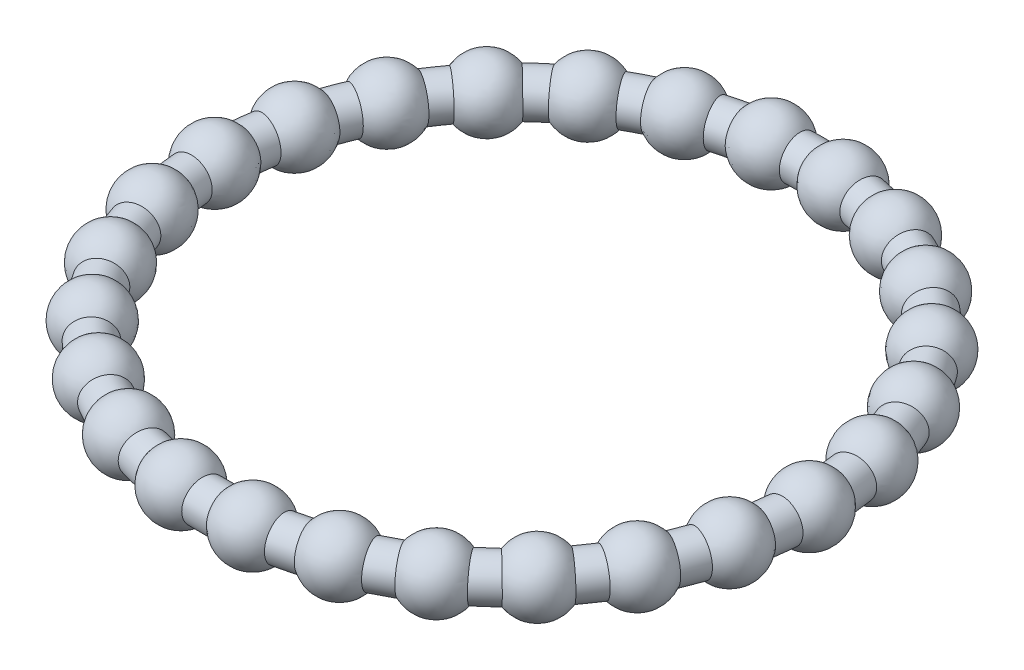
from build123d import *

# Parameters (mm, degrees)
SKETCH1_R         = 3.5
CIRPATTERN2_COUNT = 26


with BuildPart() as part:
    # Sketch1 → Revolve1 (revolve)
    with BuildSketch(Plane.XY, mode=Mode.PRIVATE) as revolve1_sk:
        with Locations((50, 0)):
            Circle(SKETCH1_R)
    revolve(revolve1_sk.sketch.rotate(Axis((0, 55, 0), (0, -1, 0)), 90), axis=Axis((0, 55, 0), (0, -1, 0)))

    # Sketch2 → Revolve2 (revolve)
    with BuildSketch(Plane.XY):
        with BuildLine():
            Line((50, 5.5), (50, -5.5))
            ThreePointArc((50, -5.5), (55.5, 0), (50, 5.5))
        make_face()
    revolve2 = revolve(axis=Axis((50, 5.5, 0), (0, -1, 0)))

    # CirPattern2: Revolve2 ×26 about axis
    cirpattern2_axis = Axis((0, 0, 0), (0, 1, 0))
    for i in range(1, CIRPATTERN2_COUNT):
        add(revolve2.rotate(cirpattern2_axis, i * 360 / CIRPATTERN2_COUNT))


solid = part.part
